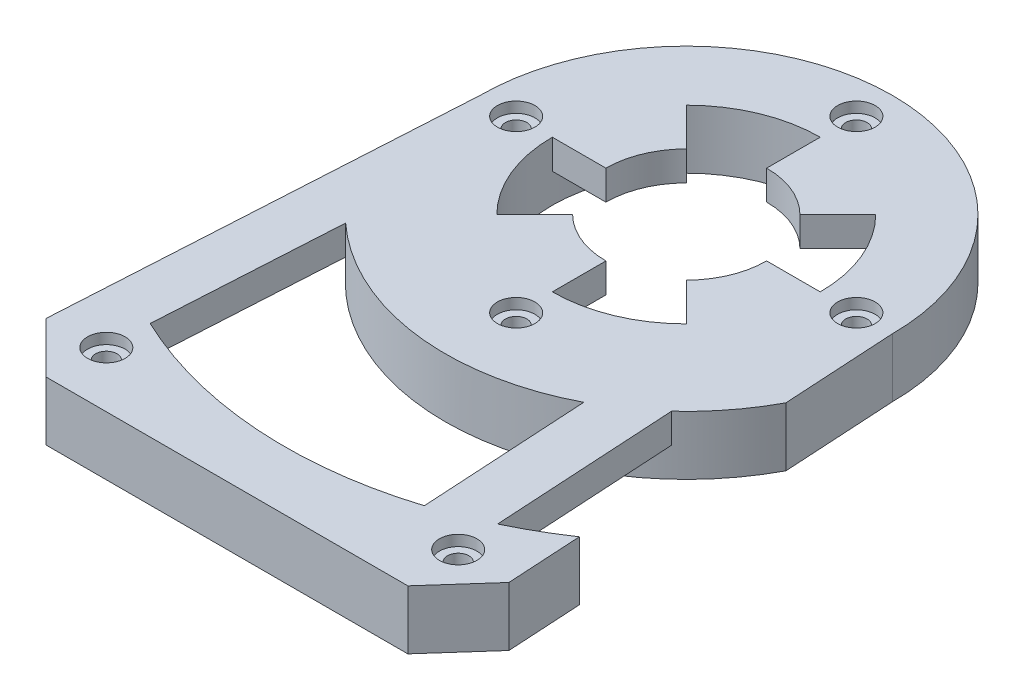
from build123d import *
from OCP.BRepFilletAPI import BRepFilletAPI_MakeChamfer
from build123d.topology import SkipClean

# Parameters (mm, degrees)
SKETCH1_R           = 38.5
BOSS_EXTRUDE1_DEPTH = 11
BOSS_EXTRUDE2_DEPTH = 11
CHAMFER1_SIZE       = 10
CHAMFER1_SIZE2      = 9.466508376
SKETCH3_R           = 15
CUT_EXTRUDE1_DEPTH  = 97.756135196
SKETCH4_R           = 25
CUT_EXTRUDE2_DEPTH  = 5.5
CUT_EXTRUDE3_DEPTH  = 5.5
CUT_EXTRUDE5_DEPTH  = 5.5
CUT_EXTRUDE6_DEPTH  = 5.5
SKETCH9_R           = 3.5
CUT_EXTRUDE7_DEPTH  = 2
SKETCH10_R          = 2
CUT_EXTRUDE8_DEPTH  = 97.549208687
CUT_EXTRUDE9_DEPTH  = 97.286030649
SKETCH13_R          = 2
CUT_EXTRUDE10_DEPTH = 97.756135196
SKETCH14_R          = 3.5
CUT_EXTRUDE11_DEPTH = 2


with BuildPart() as part:
    # Sketch1 → Boss-Extrude1 (new body)
    with BuildSketch(Plane(origin=(0, 0, 0), x_dir=(1, 0, 0), z_dir=(0, 1, 0))):
        with Locations(Location((0, 0, 0), (0, 0, 270))):
            Circle(SKETCH1_R)
    extrude(amount=BOSS_EXTRUDE1_DEPTH)

    # Sketch2 → Boss-Extrude2 (add, through all)
    with BuildSketch(Plane(origin=(0, 11, 0), x_dir=(1, 0, 0), z_dir=(0, 1, 0))):
        with BuildLine():
            Line((-38.5, 0), (-43.5, -86))
            Line((-43.5, -86), (43.5, -86))
            Line((43.5, -86), (38.5, 0))
            ThreePointArc((38.5, 0), (0, -38.5), (-38.5, 0))
        make_face()
    extrude(amount=-BOSS_EXTRUDE2_DEPTH)

    # Chamfer1: one chamfer whose edges measure the first distance from different faces: ONE call of the kernel's chamfer builder (chamfer() names one face for all edges)
    chamfer1_edges_1 = [part.edges().sort_by_distance(p)[0] for p in [
        (43.5, 5.5, 86),
    ]]
    chamfer1_side_1 = [part.faces().sort_by_distance(p)[0] for p in [
        (41, 5.5, 43),
    ]]
    chamfer1_edges_2 = [part.edges().sort_by_distance(p)[0] for p in [
        (-43.5, 5.5, 86),
    ]]
    chamfer1_side_2 = [part.faces().sort_by_distance(p)[0] for p in [
        (0, 5.5, 86),
    ]]
    chamfer1 = BRepFilletAPI_MakeChamfer(part.part.solid().wrapped)
    for e in chamfer1_edges_1:
        chamfer1.Add(CHAMFER1_SIZE, CHAMFER1_SIZE2, e.wrapped, chamfer1_side_1[0].wrapped)  # the first distance lies on this face
    for e in chamfer1_edges_2:
        chamfer1.Add(CHAMFER1_SIZE, CHAMFER1_SIZE2, e.wrapped, chamfer1_side_2[0].wrapped)  # the first distance lies on this face
    add(Compound.cast(chamfer1.Shape()), mode=Mode.REPLACE)

    # Sketch3 → Cut-Extrude1 (cut, through all)
    with BuildSketch(Plane(origin=(0, 11, 0), x_dir=(1, 0, 0), z_dir=(0, 1, 0))):
        with Locations(Location((0, 0, 0), (0, 0, 270))):
            Circle(SKETCH3_R)
    extrude(amount=-CUT_EXTRUDE1_DEPTH, mode=Mode.SUBTRACT)

    # Sketch4 → Cut-Extrude2 (cut)
    with BuildSketch(Plane.XZ):
        with Locations(Location((0, 0, 0), (0, 0, 270))):
            Circle(SKETCH4_R)
    extrude(amount=-CUT_EXTRUDE2_DEPTH, mode=Mode.SUBTRACT)

    # Sketch5 → Cut-Extrude3 (cut)
    with SkipClean():  # the faces are left unmerged after this step: merging them gives an invalid solid
        with BuildSketch(Plane(origin=(0, 11, 0), x_dir=(1, 0, 0), z_dir=(0, 1, 0))):
            with BuildLine():
                Line((25, 0), (15, 0))
                ThreePointArc((15, 0), (13.858192988, 5.740251485), (10.606601718, 10.606601718))
                Line((10.606601718, 10.606601718), (17.67766953, 17.67766953))
                ThreePointArc((17.67766953, 17.67766953), (23.096988313, 9.567085809), (25, 0))
            make_face()
            with BuildLine():
                Line((0, 25), (0, 15))
                ThreePointArc((0, 15), (-5.740251485, 13.858192988), (-10.606601718, 10.606601718))
                Line((-10.606601718, 10.606601718), (-17.67766953, 17.67766953))
                ThreePointArc((-17.67766953, 17.67766953), (-9.567085809, 23.096988313), (0, 25))
            make_face()
            with BuildLine():
                Line((10.606601718, -10.606601718), (17.67766953, -17.67766953))
                ThreePointArc((17.67766953, -17.67766953), (9.567085809, -23.096988313), (0, -25))
                Line((0, -25), (0, -15))
                ThreePointArc((0, -15), (5.740251485, -13.858192988), (10.606601718, -10.606601718))
            make_face()
            with BuildLine():
                Line((-15, 0), (-25, 0))
                ThreePointArc((-25, 0), (-23.096988313, -9.567085809), (-17.67766953, -17.67766953))
                Line((-17.67766953, -17.67766953), (-10.606601718, -10.606601718))
                ThreePointArc((-10.606601718, -10.606601718), (-13.858192988, -5.740251485), (-15, 0))
            make_face()
        extrude(amount=-CUT_EXTRUDE3_DEPTH, mode=Mode.SUBTRACT)

    # Sketch7 → Cut-Extrude5 (cut)
    with SkipClean():  # the faces are left unmerged after this step: merging them gives an invalid solid
        with BuildSketch(Plane(origin=(0, 0, 0), x_dir=(1, 0, 0), z_dir=(0, 1, 0))):
            with BuildLine():
                Line((42.108347266, -62.063572976), (39.728699574, -21.133632677))
                ThreePointArc((39.728699574, -21.133632677), (0, -45), (-39.728699574, -21.133632677))
                Line((-39.728699574, -21.133632677), (-42.108347266, -62.063572976))
                ThreePointArc((-42.108347266, -62.063572976), (0, -75), (42.108347266, -62.063572976))
            make_face()
        extrude(amount=CUT_EXTRUDE5_DEPTH, mode=Mode.SUBTRACT)

    # Sketch8 → Cut-Extrude6 (cut)
    with SkipClean():  # the faces are left unmerged after this step: merging them gives an invalid solid
        with BuildSketch(Plane(origin=(0, 11, 0), x_dir=(1, 0, 0), z_dir=(0, 1, 0))):
            with BuildLine():
                Line((-30.411506405, -33.168362609), (-32.415276079, -67.633200994))
                ThreePointArc((-32.415276079, -67.633200994), (-5.264965928, -74.814972658), (22.623578731, -71.506459047))
                Line((22.623578731, -71.506459047), (20.786653197, -39.911339853))
                ThreePointArc((20.786653197, -39.911339853), (-5.875915703, -44.614724191), (-30.411506405, -33.168362609))
            make_face()
        extrude(amount=-CUT_EXTRUDE6_DEPTH, mode=Mode.SUBTRACT)

    # Sketch9 → Cut-Extrude7 (cut)
    with SkipClean():  # the faces are left unmerged after this step: merging them gives an invalid solid
        with BuildSketch(Plane(origin=(0, 11, 0), x_dir=(1, 0, 0), z_dir=(0, 1, 0))):
            with Locations(Location((-31.75, 0, 0), (0, 0, 270))):
                Circle(SKETCH9_R)
            with Locations(Location((0, 31.75, 0), (0, 0, 270))):
                Circle(SKETCH9_R)
            with Locations(Location((31.75, 0, 0), (0, 0, 270))):
                Circle(SKETCH9_R)
            with Locations(Location((0, -31.75, 0), (0, 0, 270))):
                Circle(SKETCH9_R)
        extrude(amount=-CUT_EXTRUDE7_DEPTH, mode=Mode.SUBTRACT)

    # Sketch10 → Cut-Extrude8 (cut, through all)
    with SkipClean():  # the faces are left unmerged after this step: merging them gives an invalid solid
        with BuildSketch(Plane(origin=(0, 9, 0), x_dir=(1, 0, 0), z_dir=(0, 1, 0))):
            with Locations(Location((-31.75, 0, 0), (0, 0, 270))):
                Circle(SKETCH10_R)
            with Locations(Location((0, 31.75, 0), (0, 0, 270))):
                Circle(SKETCH10_R)
            with Locations(Location((31.75, 0, 0), (0, 0, 270))):
                Circle(SKETCH10_R)
            with Locations(Location((0, -31.75, 0), (0, 0, 270))):
                Circle(SKETCH10_R)
        extrude(amount=-CUT_EXTRUDE8_DEPTH, mode=Mode.SUBTRACT)

    # Sketch11 → Cut-Extrude9 (cut, through all)
    with SkipClean():  # the faces are left unmerged after this step: merging them gives an invalid solid
        with BuildSketch(Plane.XZ.offset(-5.5)):
            with BuildLine():
                Line((39.728699574, 21.133632677), (42.108347266, 62.063572976))
                ThreePointArc((42.108347266, 62.063572976), (37.365730264, 65.029241129), (32.415276079, 67.633200994))
                Line((32.415276079, 67.633200994), (30.411506405, 33.168362609))
                ThreePointArc((30.411506405, 33.168362609), (35.582591317, 27.547762072), (39.728699574, 21.133632677))
            make_face()
        extrude(amount=-CUT_EXTRUDE9_DEPTH, mode=Mode.SUBTRACT)

    # Sketch13 → Cut-Extrude10 (cut, through all)
    with SkipClean():  # the faces are left unmerged after this step: merging them gives an invalid solid
        with BuildSketch(Plane(origin=(0, 11, 0), x_dir=(1, 0, 0), z_dir=(0, 1, 0))):
            with Locations(Location((-32.612704984, -75.623047913, 0), (0, 0, 270))):
                Circle(SKETCH13_R)
            with Locations(Location((32.868643167, -75.439338775, 0), (0, 0, 270))):
                Circle(SKETCH13_R)
        extrude(amount=-CUT_EXTRUDE10_DEPTH, mode=Mode.SUBTRACT)

    # Sketch14 → Cut-Extrude11 (cut)
    with SkipClean():  # the faces are left unmerged after this step: merging them gives an invalid solid
        with BuildSketch(Plane(origin=(0, 11, 0), x_dir=(1, 0, 0), z_dir=(0, 1, 0))):
            with Locations(Location((-32.612704984, -75.623047913, 0), (0, 0, 270))):
                Circle(SKETCH14_R)
            with Locations(Location((32.868643167, -75.439338775, 0), (0, 0, 270))):
                Circle(SKETCH14_R)
        extrude(amount=-CUT_EXTRUDE11_DEPTH, mode=Mode.SUBTRACT)


solid = part.part
